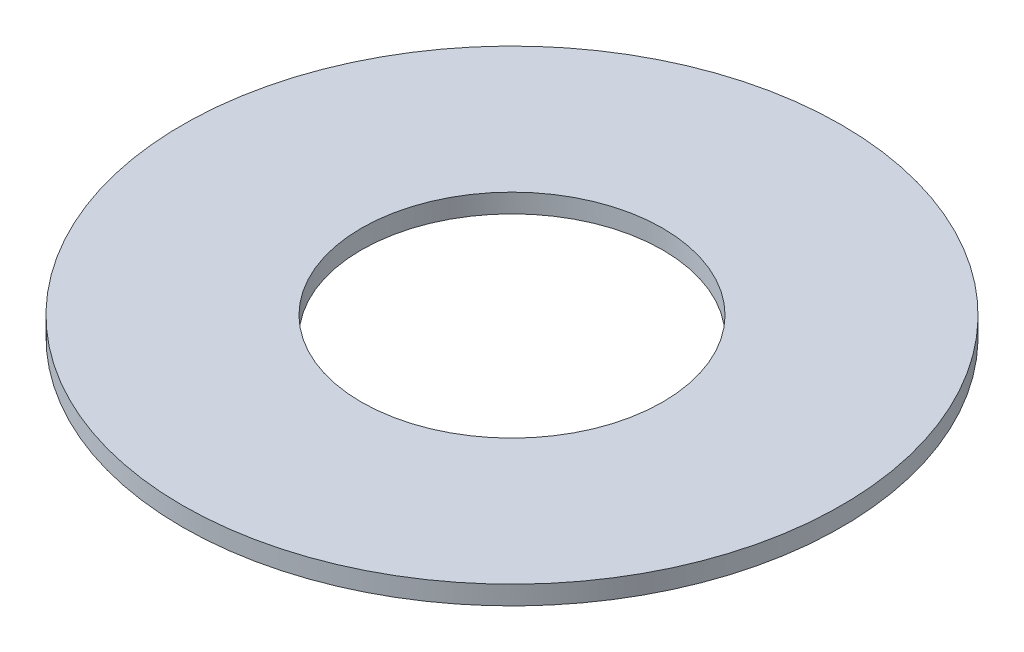
from build123d import *

# Parameters (mm, degrees)
SKETCH3_R           = 3.5
SKETCH3_R_2         = 1.6
BOSS_EXTRUDE1_DEPTH = 0.2


with BuildPart() as part:
    # Sketch3 → Boss-Extrude1 (new body)
    with BuildSketch(Plane(origin=(0, 0, 0), x_dir=(1, 0, 0), z_dir=(0, 1, 0))):
        Circle(SKETCH3_R)
        Circle(SKETCH3_R_2, mode=Mode.SUBTRACT)
    extrude(amount=BOSS_EXTRUDE1_DEPTH)


solid = part.part
